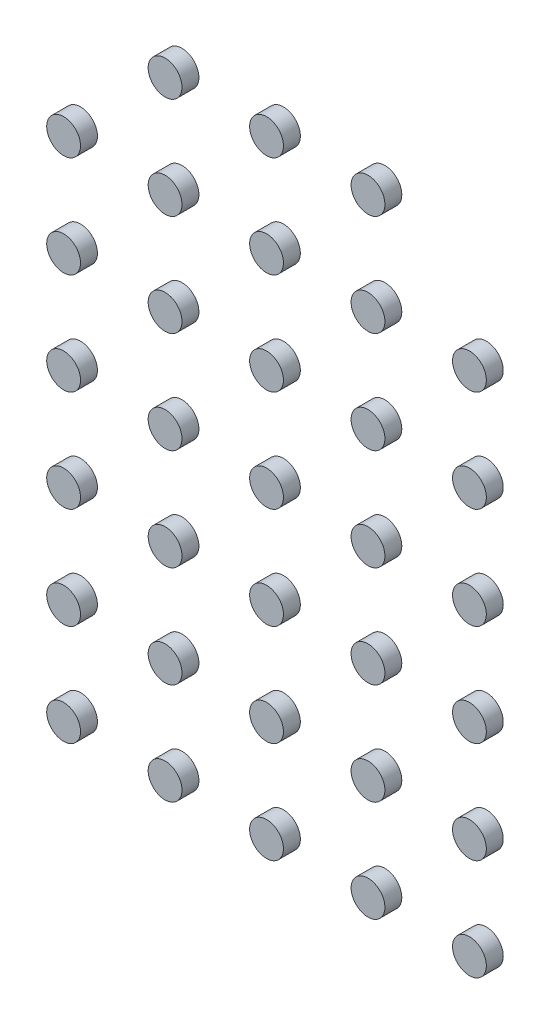
from build123d import *

# Parameters (mm, degrees)
SKETCH_4_R               = 0.5
EXTRUDE_2_DEPTH          = 0.5
PATTERN_LINEAR_1_COUNT   = 5
PATTERN_LINEAR_1_PITCH   = 3
PATTERN_LINEAR_1_2_COUNT = 7
PATTERN_LINEAR_1_2_PITCH = 3


with BuildPart() as part:
    # 草图4 → 凸台-拉伸2 (new body)
    with BuildSketch(Plane.XY):
        Circle(SKETCH_4_R)
    extrude(amount=EXTRUDE_2_DEPTH)


with BuildPart() as pattern_linear_1_1:
    # 阵列(线性)1: pattern copy
    add(part.part.moved(Location(Vector(1, 0, 0) * (1 * PATTERN_LINEAR_1_PITCH))))


with BuildPart() as pattern_linear_1_2:
    # 阵列(线性)1: pattern copy
    add(part.part.moved(Location(Vector(1, 0, 0) * (2 * PATTERN_LINEAR_1_PITCH))))


with BuildPart() as pattern_linear_1_3:
    # 阵列(线性)1: pattern copy
    add(part.part.moved(Location(Vector(1, 0, 0) * (3 * PATTERN_LINEAR_1_PITCH))))


with BuildPart() as pattern_linear_1_4:
    # 阵列(线性)1: pattern copy
    add(part.part.moved(Location(Vector(1, 0, 0) * (4 * PATTERN_LINEAR_1_PITCH))))


with BuildPart() as pattern_linear_1_2_1:
    # Pattern Linear 1 2: pattern copy
    add(part.part.moved(Location(Vector(0, 1, 0) * (1 * PATTERN_LINEAR_1_2_PITCH))))


with BuildPart() as pattern_linear_1_2_2:
    # Pattern Linear 1 2: pattern copy
    add(part.part.moved(Location(Vector(0, 1, 0) * (2 * PATTERN_LINEAR_1_2_PITCH))))


with BuildPart() as pattern_linear_1_2_3:
    # Pattern Linear 1 2: pattern copy
    add(part.part.moved(Location(Vector(0, 1, 0) * (3 * PATTERN_LINEAR_1_2_PITCH))))


with BuildPart() as pattern_linear_1_2_4:
    # Pattern Linear 1 2: pattern copy
    add(part.part.moved(Location(Vector(0, 1, 0) * (4 * PATTERN_LINEAR_1_2_PITCH))))


with BuildPart() as pattern_linear_1_2_5:
    # Pattern Linear 1 2: pattern copy
    add(part.part.moved(Location(Vector(0, 1, 0) * (5 * PATTERN_LINEAR_1_2_PITCH))))


with BuildPart() as pattern_linear_1_2_6:
    # Pattern Linear 1 2: pattern copy
    add(part.part.moved(Location(Vector(0, 1, 0) * (6 * PATTERN_LINEAR_1_2_PITCH))))


with BuildPart() as pattern_linear_1_2_7:
    # Pattern Linear 1 2: pattern copy
    add(pattern_linear_1_1.part.moved(Location(Vector(0, 1, 0) * (1 * PATTERN_LINEAR_1_2_PITCH))))


with BuildPart() as pattern_linear_1_2_8:
    # Pattern Linear 1 2: pattern copy
    add(pattern_linear_1_1.part.moved(Location(Vector(0, 1, 0) * (2 * PATTERN_LINEAR_1_2_PITCH))))


with BuildPart() as pattern_linear_1_2_9:
    # Pattern Linear 1 2: pattern copy
    add(pattern_linear_1_1.part.moved(Location(Vector(0, 1, 0) * (3 * PATTERN_LINEAR_1_2_PITCH))))


with BuildPart() as pattern_linear_1_2_10:
    # Pattern Linear 1 2: pattern copy
    add(pattern_linear_1_1.part.moved(Location(Vector(0, 1, 0) * (4 * PATTERN_LINEAR_1_2_PITCH))))


with BuildPart() as pattern_linear_1_2_11:
    # Pattern Linear 1 2: pattern copy
    add(pattern_linear_1_1.part.moved(Location(Vector(0, 1, 0) * (5 * PATTERN_LINEAR_1_2_PITCH))))


with BuildPart() as pattern_linear_1_2_12:
    # Pattern Linear 1 2: pattern copy
    add(pattern_linear_1_1.part.moved(Location(Vector(0, 1, 0) * (6 * PATTERN_LINEAR_1_2_PITCH))))


with BuildPart() as pattern_linear_1_2_13:
    # Pattern Linear 1 2: pattern copy
    add(pattern_linear_1_2.part.moved(Location(Vector(0, 1, 0) * (1 * PATTERN_LINEAR_1_2_PITCH))))


with BuildPart() as pattern_linear_1_2_14:
    # Pattern Linear 1 2: pattern copy
    add(pattern_linear_1_2.part.moved(Location(Vector(0, 1, 0) * (2 * PATTERN_LINEAR_1_2_PITCH))))


with BuildPart() as pattern_linear_1_2_15:
    # Pattern Linear 1 2: pattern copy
    add(pattern_linear_1_2.part.moved(Location(Vector(0, 1, 0) * (3 * PATTERN_LINEAR_1_2_PITCH))))


with BuildPart() as pattern_linear_1_2_16:
    # Pattern Linear 1 2: pattern copy
    add(pattern_linear_1_2.part.moved(Location(Vector(0, 1, 0) * (4 * PATTERN_LINEAR_1_2_PITCH))))


with BuildPart() as pattern_linear_1_2_17:
    # Pattern Linear 1 2: pattern copy
    add(pattern_linear_1_2.part.moved(Location(Vector(0, 1, 0) * (5 * PATTERN_LINEAR_1_2_PITCH))))


with BuildPart() as pattern_linear_1_2_18:
    # Pattern Linear 1 2: pattern copy
    add(pattern_linear_1_2.part.moved(Location(Vector(0, 1, 0) * (6 * PATTERN_LINEAR_1_2_PITCH))))


with BuildPart() as pattern_linear_1_2_19:
    # Pattern Linear 1 2: pattern copy
    add(pattern_linear_1_3.part.moved(Location(Vector(0, 1, 0) * (1 * PATTERN_LINEAR_1_2_PITCH))))


with BuildPart() as pattern_linear_1_2_20:
    # Pattern Linear 1 2: pattern copy
    add(pattern_linear_1_3.part.moved(Location(Vector(0, 1, 0) * (2 * PATTERN_LINEAR_1_2_PITCH))))


with BuildPart() as pattern_linear_1_2_21:
    # Pattern Linear 1 2: pattern copy
    add(pattern_linear_1_3.part.moved(Location(Vector(0, 1, 0) * (3 * PATTERN_LINEAR_1_2_PITCH))))


with BuildPart() as pattern_linear_1_2_22:
    # Pattern Linear 1 2: pattern copy
    add(pattern_linear_1_3.part.moved(Location(Vector(0, 1, 0) * (4 * PATTERN_LINEAR_1_2_PITCH))))


with BuildPart() as pattern_linear_1_2_23:
    # Pattern Linear 1 2: pattern copy
    add(pattern_linear_1_3.part.moved(Location(Vector(0, 1, 0) * (5 * PATTERN_LINEAR_1_2_PITCH))))


with BuildPart() as pattern_linear_1_2_24:
    # Pattern Linear 1 2: pattern copy
    add(pattern_linear_1_3.part.moved(Location(Vector(0, 1, 0) * (6 * PATTERN_LINEAR_1_2_PITCH))))


with BuildPart() as pattern_linear_1_2_25:
    # Pattern Linear 1 2: pattern copy
    add(pattern_linear_1_4.part.moved(Location(Vector(0, 1, 0) * (1 * PATTERN_LINEAR_1_2_PITCH))))


with BuildPart() as pattern_linear_1_2_26:
    # Pattern Linear 1 2: pattern copy
    add(pattern_linear_1_4.part.moved(Location(Vector(0, 1, 0) * (2 * PATTERN_LINEAR_1_2_PITCH))))


with BuildPart() as pattern_linear_1_2_27:
    # Pattern Linear 1 2: pattern copy
    add(pattern_linear_1_4.part.moved(Location(Vector(0, 1, 0) * (3 * PATTERN_LINEAR_1_2_PITCH))))


with BuildPart() as pattern_linear_1_2_28:
    # Pattern Linear 1 2: pattern copy
    add(pattern_linear_1_4.part.moved(Location(Vector(0, 1, 0) * (4 * PATTERN_LINEAR_1_2_PITCH))))


with BuildPart() as pattern_linear_1_2_29:
    # Pattern Linear 1 2: pattern copy
    add(pattern_linear_1_4.part.moved(Location(Vector(0, 1, 0) * (5 * PATTERN_LINEAR_1_2_PITCH))))


with BuildPart() as pattern_linear_1_2_30:
    # Pattern Linear 1 2: pattern copy
    add(pattern_linear_1_4.part.moved(Location(Vector(0, 1, 0) * (6 * PATTERN_LINEAR_1_2_PITCH))))


solid = Compound([part.part, pattern_linear_1_1.part, pattern_linear_1_2.part, pattern_linear_1_3.part, pattern_linear_1_4.part, pattern_linear_1_2_1.part, pattern_linear_1_2_2.part, pattern_linear_1_2_3.part, pattern_linear_1_2_4.part, pattern_linear_1_2_5.part, pattern_linear_1_2_7.part, pattern_linear_1_2_8.part, pattern_linear_1_2_9.part, pattern_linear_1_2_10.part, pattern_linear_1_2_11.part, pattern_linear_1_2_12.part, pattern_linear_1_2_13.part, pattern_linear_1_2_14.part, pattern_linear_1_2_15.part, pattern_linear_1_2_16.part, pattern_linear_1_2_17.part, pattern_linear_1_2_18.part, pattern_linear_1_2_19.part, pattern_linear_1_2_20.part, pattern_linear_1_2_21.part, pattern_linear_1_2_22.part, pattern_linear_1_2_23.part, pattern_linear_1_2_24.part, pattern_linear_1_2_25.part, pattern_linear_1_2_26.part, pattern_linear_1_2_27.part, pattern_linear_1_2_28.part, pattern_linear_1_2_29.part])
